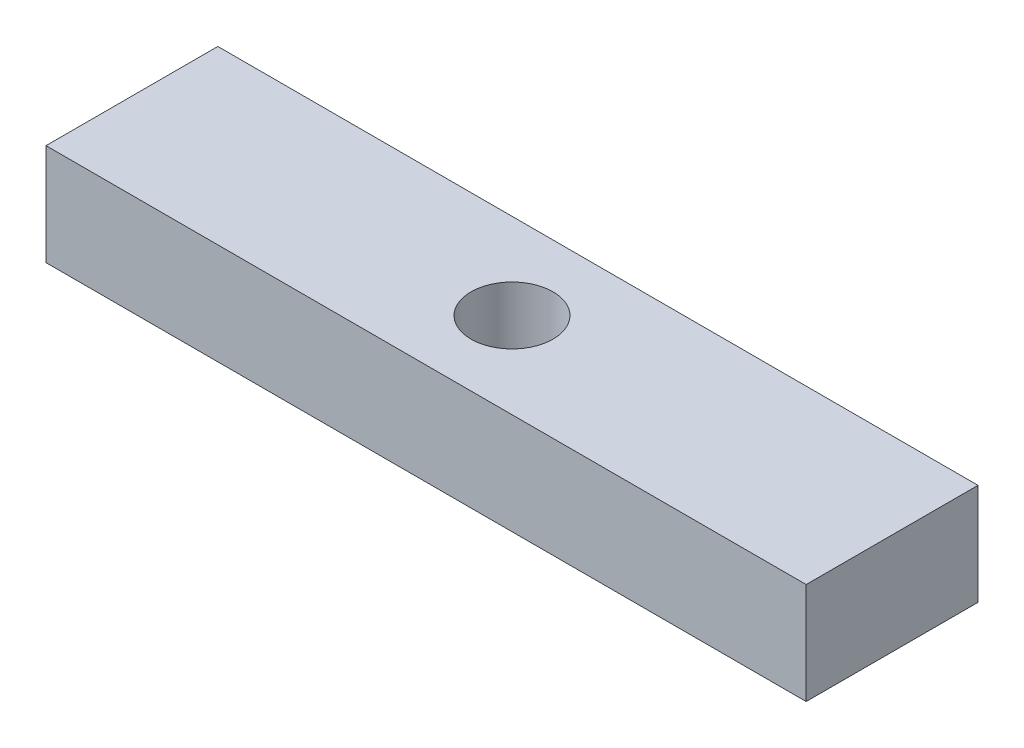
from build123d import *

# Parameters (mm, degrees)
SKETCH1_W           = 40.005
SKETCH1_H           = 9.0424
BOSS_EXTRUDE1_DEPTH = 5.334
SKETCH2_R           = 2.159
CUT_EXTRUDE1_DEPTH  = 6.334


with BuildPart() as part:
    # Sketch1 → Boss-Extrude1 (new body)
    with BuildSketch(Plane(origin=(0, 0, 0), x_dir=(1, 0, 0), z_dir=(0, 1, 0))):
        Rectangle(SKETCH1_W, SKETCH1_H)
    extrude(amount=BOSS_EXTRUDE1_DEPTH)

    # Sketch2 → Cut-Extrude1 (cut, through all)
    with BuildSketch(Plane(origin=(0, 5.334, 0), x_dir=(1, 0, 0), z_dir=(0, 1, 0))):
        Circle(SKETCH2_R)
    extrude(amount=-CUT_EXTRUDE1_DEPTH, mode=Mode.SUBTRACT)


solid = part.part
